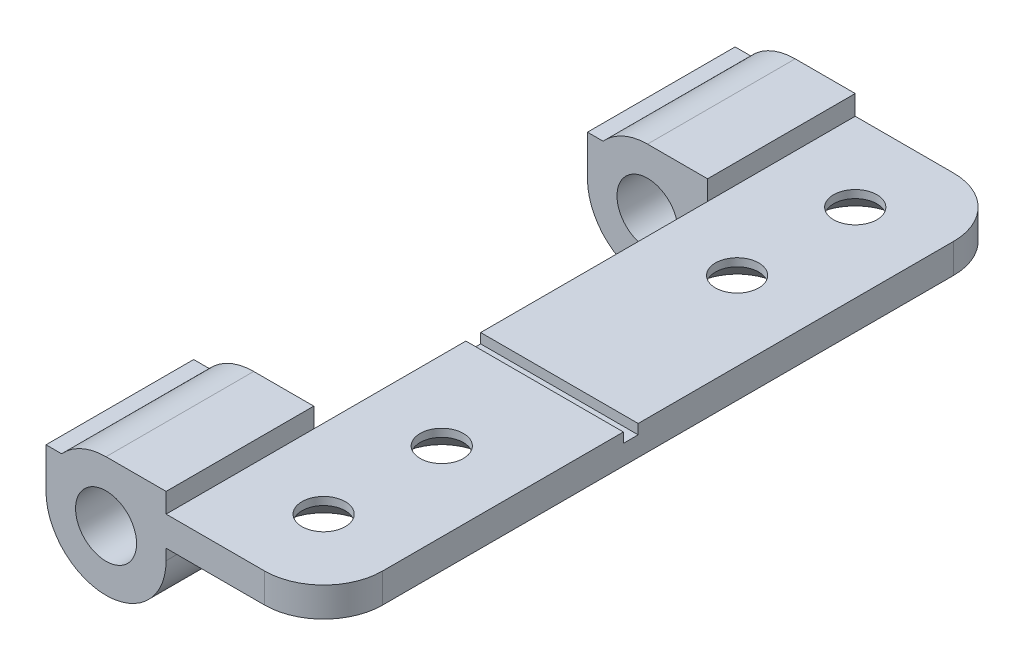
from build123d import *

# Parameters (mm, degrees)
SKETCH2_R           = 1.55
BOSS_EXTRUDE1_DEPTH = 7.5
SKETCH4_W           = 8
SKETCH4_H           = 1.5
BOSS_EXTRUDE3_DEPTH = 20
SKETCH5_R           = 1.55
BOSS_EXTRUDE4_DEPTH = 7.5
SKETCH6_W           = 0.75
SKETCH6_H           = 0.5
CUT_EXTRUDE1_DEPTH  = 9
SKETCH7_R           = 1.1
CUT_EXTRUDE2_DEPTH  = 3.5
CHAMFER1_SIZE       = 1.1
FILLET1_R           = 3


with BuildPart() as part:
    # Sketch2 → Boss-Extrude1 (new body)
    with BuildSketch(Plane.XY):
        with BuildLine():
            Line((3.05, 2.05), (11.05, 2.05))
            Line((11.05, 2.05), (11.05, 0.55))
            Line((11.05, 0.55), (3.05, 0.55))
            Line((3.05, 0.55), (3.05, 0))
            ThreePointArc((3.05, 0), (0, -3.05), (-3.05, 0))
            Line((-3.05, 0), (-3.05, 2.05))
            Line((-3.05, 2.05), (-2.258317958, 2.05))
            ThreePointArc((-2.258317958, 2.05), (-1.234908904, 2.788816953), (0, 3.05))
            Line((0, 3.05), (3.05, 3.05))
            Line((3.05, 3.05), (3.05, 2.05))
        make_face()
        Circle(SKETCH2_R, mode=Mode.SUBTRACT)
    extrude(amount=BOSS_EXTRUDE1_DEPTH)

    # Sketch4 → Boss-Extrude3 (add)
    with BuildSketch(Plane.XY.offset(7.5)):
        with Locations((7.05, 1.3)):
            Rectangle(SKETCH4_W, SKETCH4_H)
    extrude(amount=BOSS_EXTRUDE3_DEPTH)

    # Sketch5 → Boss-Extrude4 (add)
    with BuildSketch(Plane.XY.offset(27.5)):
        with BuildLine():
            Line((11.05, 0.55), (11.05, 2.05))
            Line((11.05, 2.05), (3.05, 2.05))
            Line((3.05, 2.05), (3.05, 3.05))
            Line((3.05, 3.05), (0, 3.05))
            ThreePointArc((0, 3.05), (-1.234908904, 2.788816953), (-2.258317958, 2.05))
            Line((-2.258317958, 2.05), (-3.05, 2.05))
            Line((-3.05, 2.05), (-3.05, 0))
            ThreePointArc((-3.05, 0), (0, -3.05), (3.05, 0))
            Line((3.05, 0), (3.05, 0.55))
            Line((3.05, 0.55), (11.05, 0.55))
        make_face()
        Circle(SKETCH5_R, mode=Mode.SUBTRACT)
    extrude(amount=BOSS_EXTRUDE4_DEPTH)

    # Sketch6 → Cut-Extrude1 (cut, through all)
    with BuildSketch(Plane.ZY.offset(-3.05)):
        with Locations((19.4, 1.8)):
            Rectangle(SKETCH6_W, SKETCH6_H)
    extrude(amount=-CUT_EXTRUDE1_DEPTH, mode=Mode.SUBTRACT)

    # Sketch7 → Cut-Extrude2 (cut, through all)
    with BuildSketch(Plane.XZ.offset(-0.55)):
        with Locations((7.05, 25)):
            Circle(SKETCH7_R)
        with Locations((7.05, 10)):
            Circle(SKETCH7_R)
        with Locations((7.05, 31)):
            Circle(SKETCH7_R)
        with Locations((7.05, 4)):
            Circle(SKETCH7_R)
    extrude(amount=-CUT_EXTRUDE2_DEPTH, mode=Mode.SUBTRACT)

    # Chamfer1
    chamfer1_edges = [part.edges().sort_by_distance(p)[0] for p in [
        (5.95, 0.55, 10),
        (5.95, 0.55, 25),
        (5.95, 0.55, 4),
        (5.95, 0.55, 31),
    ]]
    chamfer(chamfer1_edges, length=CHAMFER1_SIZE)

    # Fillet1
    fillet1_edges = [part.edges().sort_by_distance(p)[0] for p in [
        (11.05, 1.3, 0),
        (11.05, 1.3, 35),
    ]]
    fillet(fillet1_edges, radius=FILLET1_R)


solid = part.part
